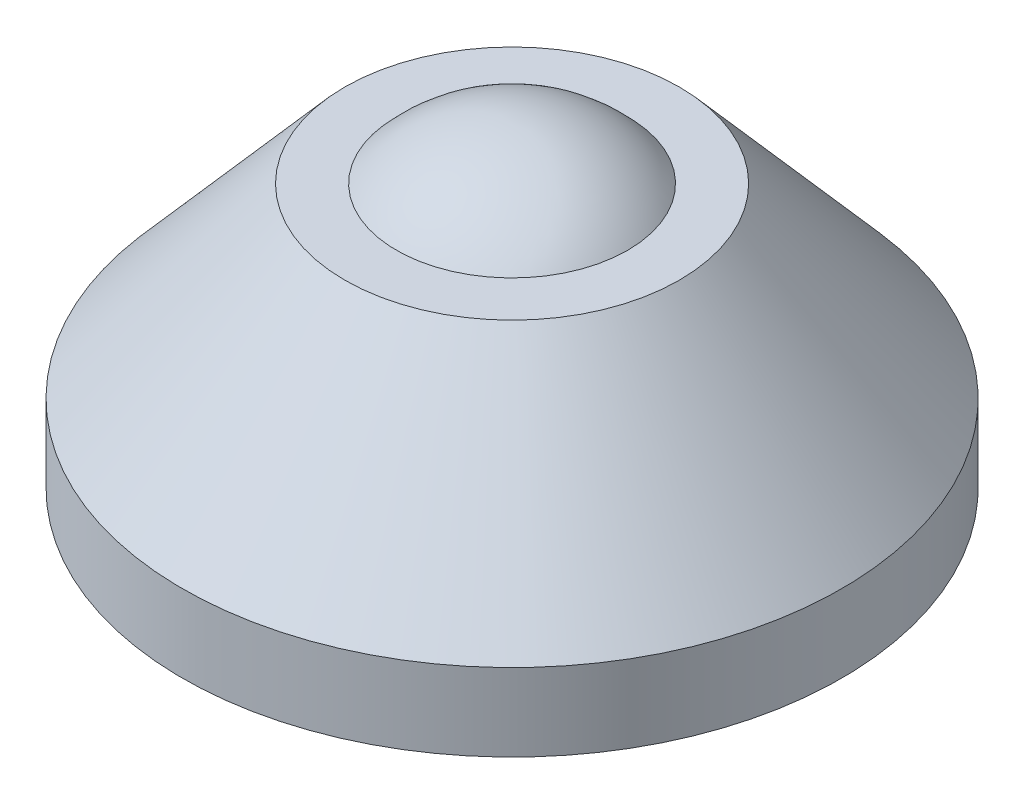
from build123d import *


with BuildPart() as part:
    # Esquisse1 → Révolution1 (revolve)
    with BuildSketch(Plane.XY):
        with BuildLine():
            Line((12.75, -3.2), (12.75, -6.2))
            Line((12.75, -6.2), (1.5, -6.2))
            Line((1.5, -6.2), (1.5, -10.7))
            Line((1.5, -10.7), (0, -10.7))
            Line((0, -10.7), (0, 6))
            ThreePointArc((0, 6), (2.449489743, 5.477225575), (4.472135955, 4))
            Line((4.472135955, 4), (6.472135955, 4))
            Line((6.472135955, 4), (12.75, -3.2))
        make_face()
    revolve(axis=Axis((0, 6, 0), (0, -1, 0)))


solid = part.part
